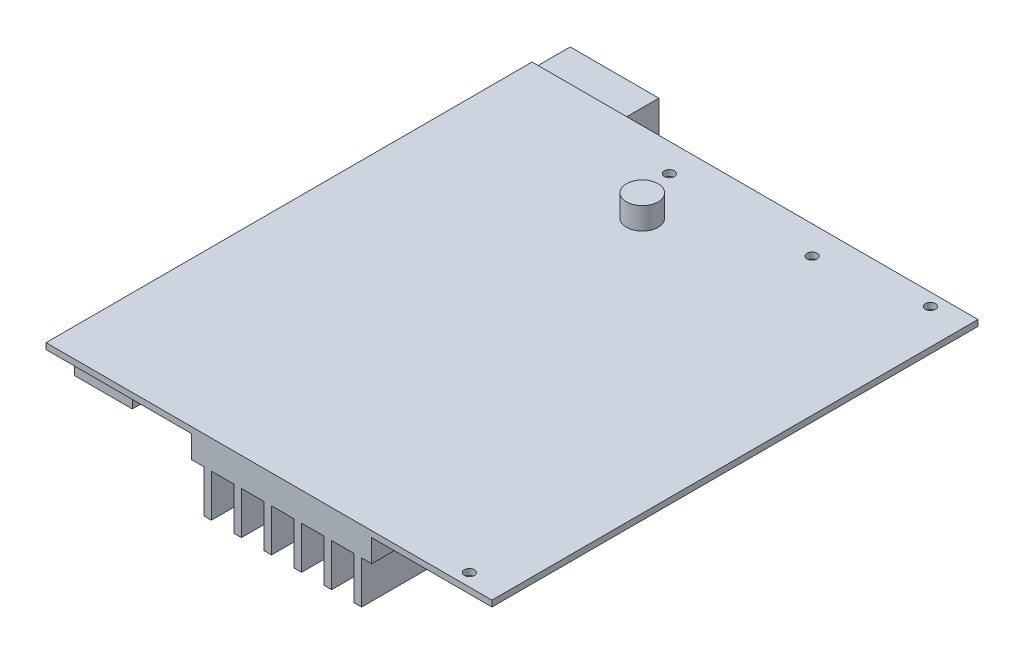
from build123d import *

# Parameters (mm, degrees)
SKETCH_1_W      = 89
SKETCH_1_H      = 97
SKETCH_1_R      = 1
EXTRUDE_1_DEPTH = 1.2
SKETCH_2_R      = 3.15
EXTRUDE_2_DEPTH = 4.4
SKETCH_3_W      = 36
SKETCH_3_H      = 97
EXTRUDE_3_DEPTH = 4.5
SKETCH_4_W      = 1.5
SKETCH_4_H      = 8.5
EXTRUDE_5_DEPTH = 97
SKETCH_5_W      = 13.6
SKETCH_5_H      = 13.1
EXTRUDE_6_DEPTH = 7.3
SKETCH_6_W      = 17.7
SKETCH_6_H      = 15.2
EXTRUDE_7_DEPTH = 14.8
SKETCH_7_W      = 11.5
SKETCH_7_H      = 9.5
EXTRUDE_8_DEPTH = 7.38


with BuildPart() as part:
    # 草图1 → 凸台-拉伸1 (new body)
    with BuildSketch(Plane(origin=(0, 0, 0), x_dir=(1, 0, 0), z_dir=(0, 1, 0))):
        with Locations((-44.5, 48.5)):
            Rectangle(SKETCH_1_W, SKETCH_1_H)
        with Locations((-7, 94.5)):
            Circle(SKETCH_1_R, mode=Mode.SUBTRACT)
        with Locations((-7, 2.5)):
            Circle(SKETCH_1_R, mode=Mode.SUBTRACT)
        with Locations((-56, 91.4)):
            Circle(SKETCH_1_R, mode=Mode.SUBTRACT)
        with Locations((-27.5, 91.4)):
            Circle(SKETCH_1_R, mode=Mode.SUBTRACT)
    extrude(amount=EXTRUDE_1_DEPTH)

    # 草图2 → 凸台-拉伸2 (add)
    with BuildSketch(Plane(origin=(0, 1.2, 0), x_dir=(1, 0, 0), z_dir=(0, 1, 0))):
        with Locations((-51, 81)):
            Circle(SKETCH_2_R)
    extrude(amount=EXTRUDE_2_DEPTH)

    # 草图3 → 凸台-拉伸3 (add)
    with BuildSketch(Plane.XZ):
        with Locations((-42, -48.5)):
            Rectangle(SKETCH_3_W, SKETCH_3_H)
    extrude(amount=EXTRUDE_3_DEPTH)

    # 草图4 → 凸台-拉伸5 (add, through all)
    with BuildSketch(Plane(origin=(0, 0, -97), x_dir=(-1, 0, 0), z_dir=(0, 0, -1))):
        with Locations((26.75, -8.75)):
            Rectangle(SKETCH_4_W, SKETCH_4_H)
        with Locations((32.75, -8.75)):
            Rectangle(SKETCH_4_W, SKETCH_4_H)
        with Locations((38.75, -8.75)):
            Rectangle(SKETCH_4_W, SKETCH_4_H)
        with Locations((44.75, -8.75)):
            Rectangle(SKETCH_4_W, SKETCH_4_H)
        with Locations((50.75, -8.75)):
            Rectangle(SKETCH_4_W, SKETCH_4_H)
        with Locations((56.75, -8.75)):
            Rectangle(SKETCH_4_W, SKETCH_4_H)
    extrude(amount=-EXTRUDE_5_DEPTH)

    # 草图5 → 凸台-拉伸6 (add)
    with BuildSketch(Plane.XZ):
        with Locations((-82.2, -63.4)):
            Rectangle(SKETCH_5_W, SKETCH_5_H)
    extrude(amount=EXTRUDE_6_DEPTH)

    # 草图6 → 凸台-拉伸7 (add)
    with BuildSketch(Plane.XZ):
        with Locations((-80.15, -97.01)):
            Rectangle(SKETCH_6_W, SKETCH_6_H)
    extrude(amount=EXTRUDE_7_DEPTH)

    # 草图7 → 凸台-拉伸8 (add)
    with BuildSketch(Plane.XZ):
        with Locations((-83.25, -10.48)):
            Rectangle(SKETCH_7_W, SKETCH_7_H)
    extrude(amount=EXTRUDE_8_DEPTH)


solid = part.part
